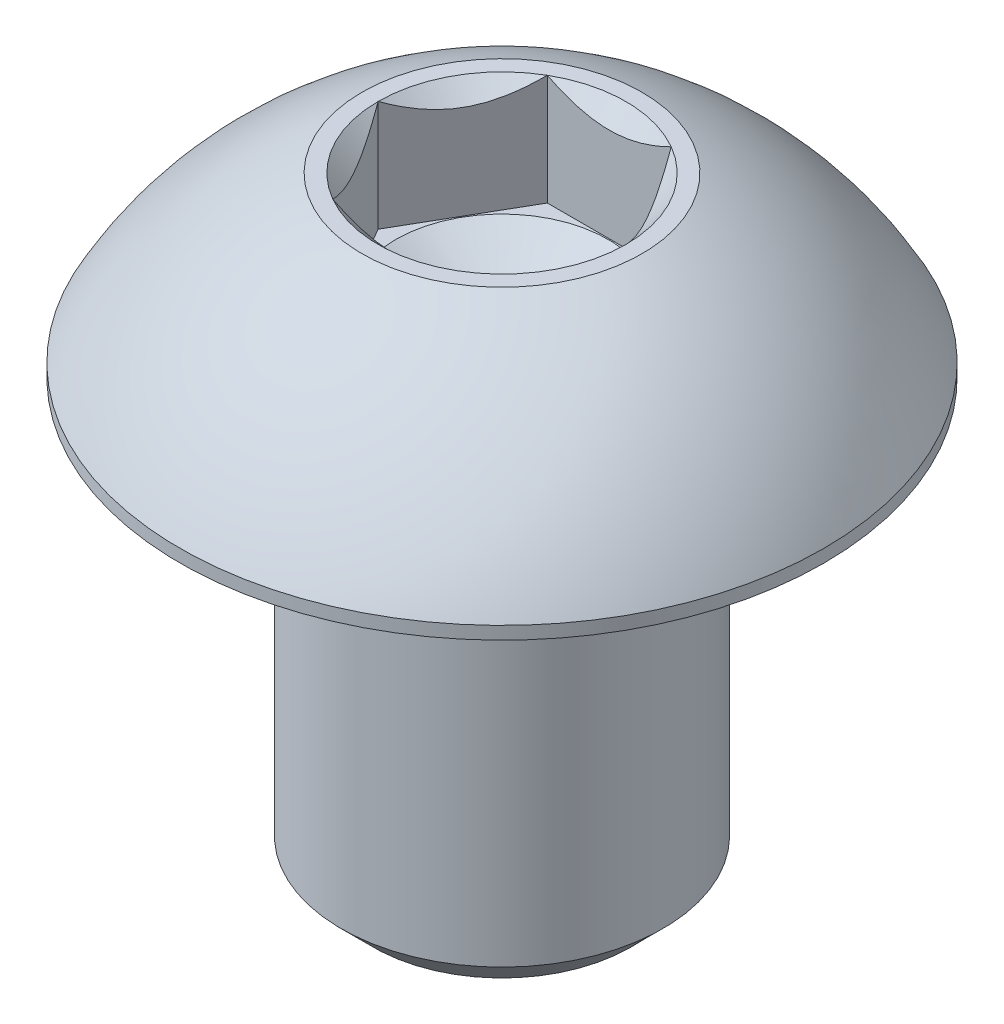
from build123d import *

# Parameters (mm, degrees)
SCHNITT_LINEAR_AUSTRAGEN1_DEPTH = 2.0625


with BuildPart() as part:
    # Skizze1 → Rotation1 (revolve)
    with BuildSketch(Plane(origin=(0, 0, 0), x_dir=(1, 0, 0), z_dir=(0, 0, -1)), mode=Mode.PRIVATE) as rotation1_sk:
        with BuildLine():
            Line((0, 11.3), (2.4, 11.3))
            Line((2.4, 11.3), (3, 10.7))
            Line((3, 10.7), (3, 3.3))
            Line((3, 3.3), (6, 3.3))
            Line((6, 3.3), (6, 3.06135))
            ThreePointArc((6, 3.06135), (4.568743009, 1.238234699), (2.609401077, 0))
            Line((2.609401077, 0), (2.309401077, 0))
            Line((2.309401077, 0), (1.98, 0.329401077))
            Line((1.98, 0.329401077), (1.98, 2.0625))
            Line((1.98, 2.0625), (0, 3.252204026))
            Line((0, 3.252204026), (0, 11.3))
        make_face()
    revolve(rotation1_sk.sketch.rotate(Axis((0, 0, 0), (0, -1, 0)), 180), axis=Axis((0, 0, 0), (0, -1, 0)))  # turned: the seam where the file's is

    # Skizze2 → Schnitt-Linear austragen1 (cut)
    with BuildSketch(Plane(origin=(1.973616694, 0, -1.468825329), x_dir=(-1, 0, 0), z_dir=(0, 1, 0))):
        Polygon((0.818916155, -0.531174671), (3.128317232, -0.531174671), (4.28301777, 1.468825329), (3.128317232, 3.468825329), (0.818916155, 3.468825329), (-0.335784383, 1.468825329), align=None)
    extrude(amount=-SCHNITT_LINEAR_AUSTRAGEN1_DEPTH, mode=Mode.SUBTRACT)


solid = part.part
